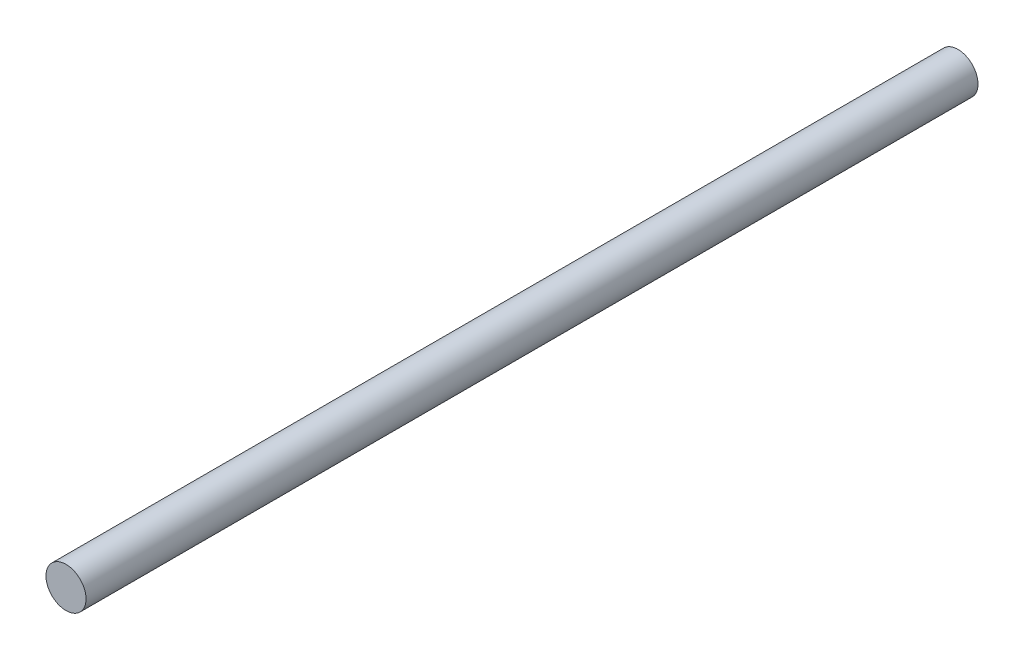
from build123d import *

# Parameters (mm, degrees)
SKETCH1_R           = 4
BOSS_EXTRUDE1_DEPTH = 89


with BuildPart() as part:
    # Sketch1 → Boss-Extrude1 (new body, symmetric)
    with BuildSketch(Plane.XY):
        Circle(SKETCH1_R)
    extrude(amount=BOSS_EXTRUDE1_DEPTH, both=True)


solid = part.part
